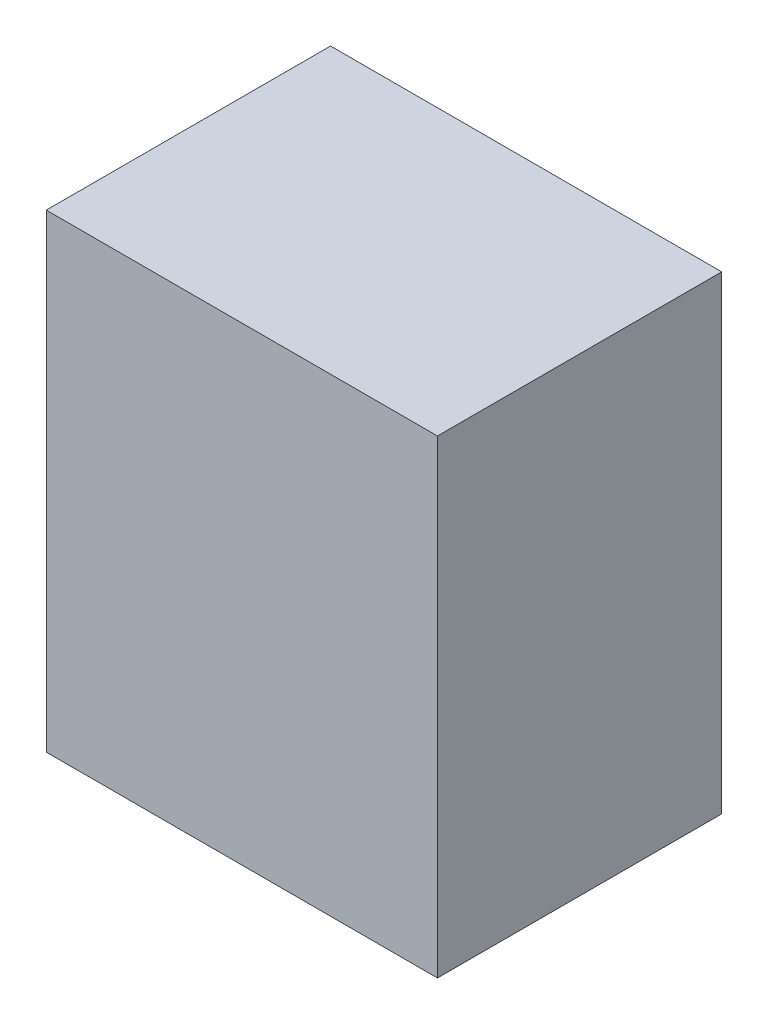
from build123d import *

# Parameters (mm, degrees)
SKETCH1_W           = 38.1
SKETCH1_H           = 45.72
BOSS_EXTRUDE1_DEPTH = 27.686


with BuildPart() as part:
    # Sketch1 → Boss-Extrude1 (new body)
    with BuildSketch(Plane.XY):
        with Locations((19.05, 22.86)):
            Rectangle(SKETCH1_W, SKETCH1_H)
    extrude(amount=BOSS_EXTRUDE1_DEPTH)


solid = part.part
